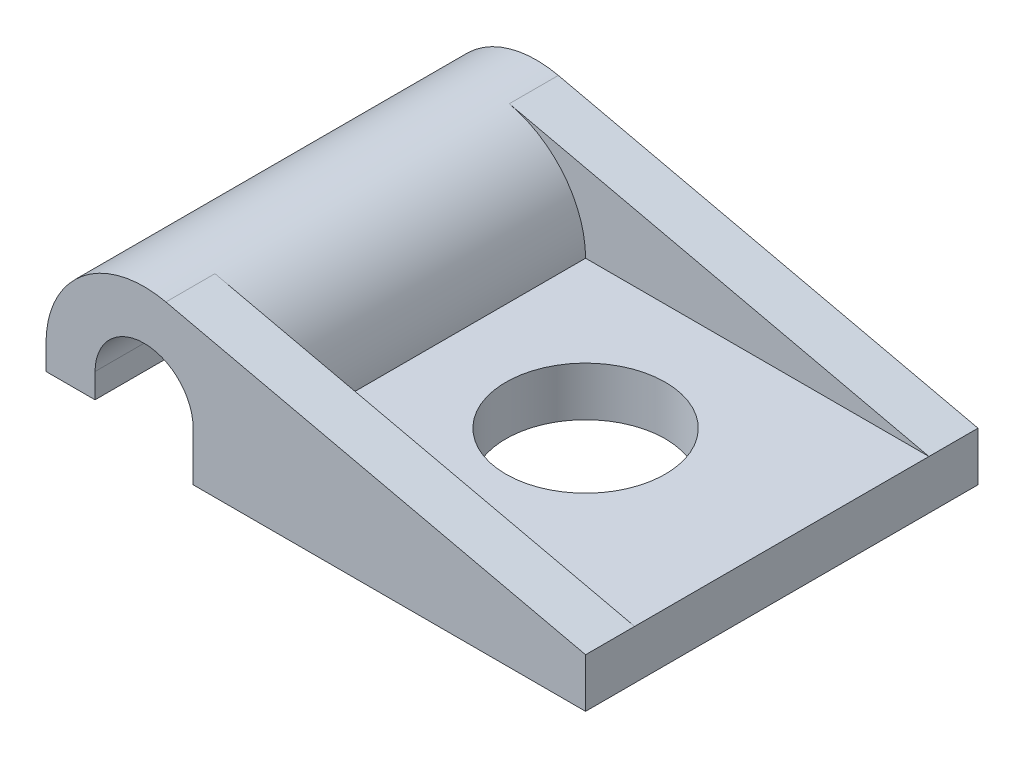
from build123d import *

# Parameters (mm, degrees)
BOSS_EXTRUDE1_DEPTH            = 6.35
CUT_EXTRUDE3_START             = 1.5875
SKETCH4_W                      = 11.1125
SKETCH4_H                      = 9.525
CUT_EXTRUDE3_DEPTH             = 4.175
CUT_EXTRUDE4_REACH             = 8.35
CUT_EXTRUDE4_DIRECTION_2_REACH = 8.35
SKETCH3_R                      = 2.579687
CUT_EXTRUDE2_DEPTH             = 2.54


with BuildPart() as part:
    # Sketch1 → Boss-Extrude1 (new body, symmetric)
    with BuildSketch(Plane.XY):
        with BuildLine():
            Line((-3.175, 0.79375), (-3.175, 1.5875))
            ThreePointArc((-3.175, 1.5875), (-1.97996, 4.069512), (0.705556, 4.683112))
            Line((0.705556, 4.683112), (14.2875, 1.5875))
            Line((14.2875, 1.5875), (14.2875, 0))
            Line((14.2875, 0), (1.5875, 0))
            Line((1.5875, 0), (1.5875, 1.5875))
            ThreePointArc((1.5875, 1.5875), (0, 3.175), (-1.5875, 1.5875))
            Line((-1.5875, 1.5875), (-1.5875, 0.79375))
            Line((-1.5875, 0.79375), (-3.175, 0.79375))
        make_face()
    extrude(amount=BOSS_EXTRUDE1_DEPTH, both=True)

    # Sketch4 → Cut-Extrude3 (cut, through all)
    with BuildSketch(Plane(origin=(0, 0, 0), x_dir=(1, 0, 0), z_dir=(0, 1, 0)).offset(CUT_EXTRUDE3_START)):
        with Locations((8.73125, 0)):
            Rectangle(SKETCH4_W, SKETCH4_H)
    extrude(amount=CUT_EXTRUDE3_DEPTH, mode=Mode.SUBTRACT)

    # Cut-Extrude4: up to this face of the body (flat: up to its plane)
    cut_extrude4_end = Plane(part.part.faces().sort_by_distance((6.879167, 2.431758, 4.7625))[0])
    # Sketch5 → Cut-Extrude4 (cut, up to the picked face)
    with BuildSketch(Plane.XY, mode=Mode.PRIVATE) as cut_extrude4_sk1:
        with BuildLine():
            Line((3.175, 1.5875), (3.175, 4.120274))
            Line((3.175, 4.120274), (0.705556, 4.683112))
            ThreePointArc((0.705556, 4.683112), (2.482012, 3.56746), (3.175, 1.5875))
        make_face()
    cut_extrude4_tool1 = split(extrude(cut_extrude4_sk1.sketch, amount=CUT_EXTRUDE4_REACH, mode=Mode.PRIVATE), bisect_by=cut_extrude4_end, keep=Keep.BOTH, mode=Mode.PRIVATE)
    add(cut_extrude4_tool1.solids().sort_by_distance((2.639834, 3.693359, 0))[0], mode=Mode.SUBTRACT)

    # Cut-Extrude4 direction 2: up to this face of the body (flat: up to its plane)
    cut_extrude4_direction_2_end = Plane(part.part.faces().sort_by_distance((6.879167, 2.431758, -4.7625))[0])
    # Sketch5 → Cut-Extrude4 direction 2 (cut, up to the picked face)
    with BuildSketch(Plane.XY, mode=Mode.PRIVATE) as cut_extrude4_direction_2_sk1:
        with BuildLine():
            Line((3.175, 1.5875), (3.175, 4.120274))
            Line((3.175, 4.120274), (0.705556, 4.683112))
            ThreePointArc((0.705556, 4.683112), (2.482012, 3.56746), (3.175, 1.5875))
        make_face()
    cut_extrude4_direction_2_tool1 = split(extrude(cut_extrude4_direction_2_sk1.sketch, amount=-CUT_EXTRUDE4_DIRECTION_2_REACH, mode=Mode.PRIVATE), bisect_by=cut_extrude4_direction_2_end, keep=Keep.BOTH, mode=Mode.PRIVATE)
    add(cut_extrude4_direction_2_tool1.solids().sort_by_distance((2.639834, 3.693359, 0))[0], mode=Mode.SUBTRACT)

    # Sketch3 → Cut-Extrude2 (cut)
    with BuildSketch(Plane(origin=(0, 0, 0), x_dir=(1, 0, 0), z_dir=(0, 1, 0))):
        with Locations((7.9375, 0)):
            Circle(SKETCH3_R)
    extrude(amount=CUT_EXTRUDE2_DEPTH, mode=Mode.SUBTRACT)


solid = part.part
